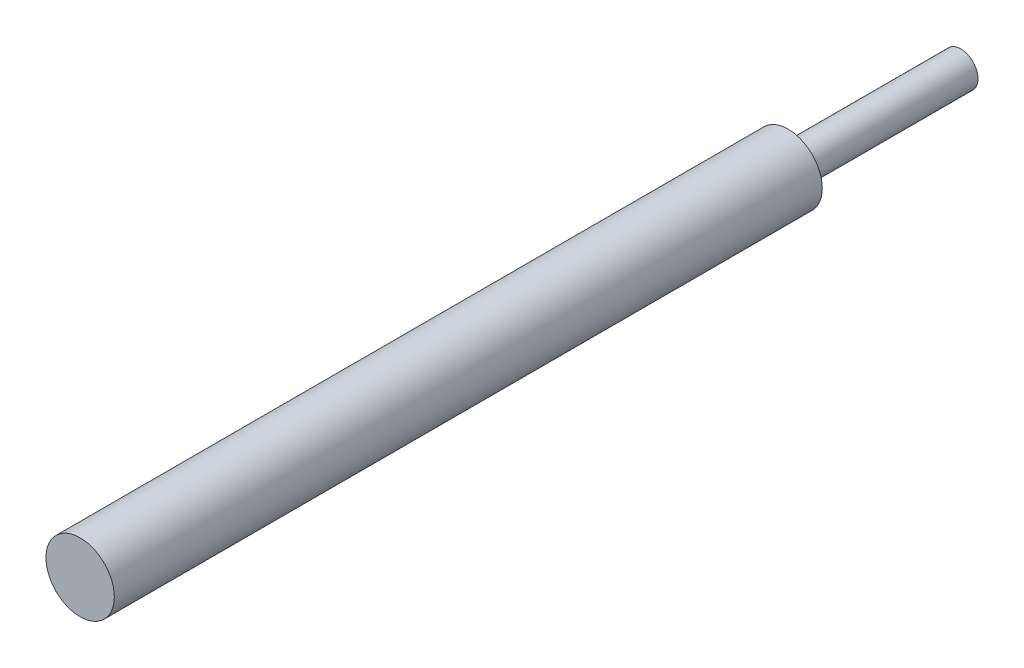
from build123d import *

# Parameters (mm, degrees)
IZIM1_R                          = 9.9
Y_KSEKLIK_EKSTR_ZYON1_DEPTH      = 149
Y_KSEKLIK_EKSTR_ZYON1_DEPTH_BACK = 106
IZIM4_R                          = 9.9
IZIM4_R_2                        = 5
KES_EKSTR_ZYON4_DEPTH            = 50


with BuildPart() as part:
    # Çizim1 → Yükseklik-Ekstrüzyon1 (new body, two sides)
    with BuildSketch(Plane.XY) as y_kseklik_ekstr_zyon1_sk:
        Circle(IZIM1_R)
    extrude(amount=Y_KSEKLIK_EKSTR_ZYON1_DEPTH)
    extrude(y_kseklik_ekstr_zyon1_sk.sketch, amount=-Y_KSEKLIK_EKSTR_ZYON1_DEPTH_BACK)

    # Çizim4 → Kes-Ekstrüzyon4 (cut)
    with BuildSketch(Plane(origin=(0, 0, -106), x_dir=(-1, 0, 0), z_dir=(0, 0, -1))):
        Circle(IZIM4_R)
        Circle(IZIM4_R_2, mode=Mode.SUBTRACT)
    extrude(amount=-KES_EKSTR_ZYON4_DEPTH, mode=Mode.SUBTRACT)


solid = part.part
